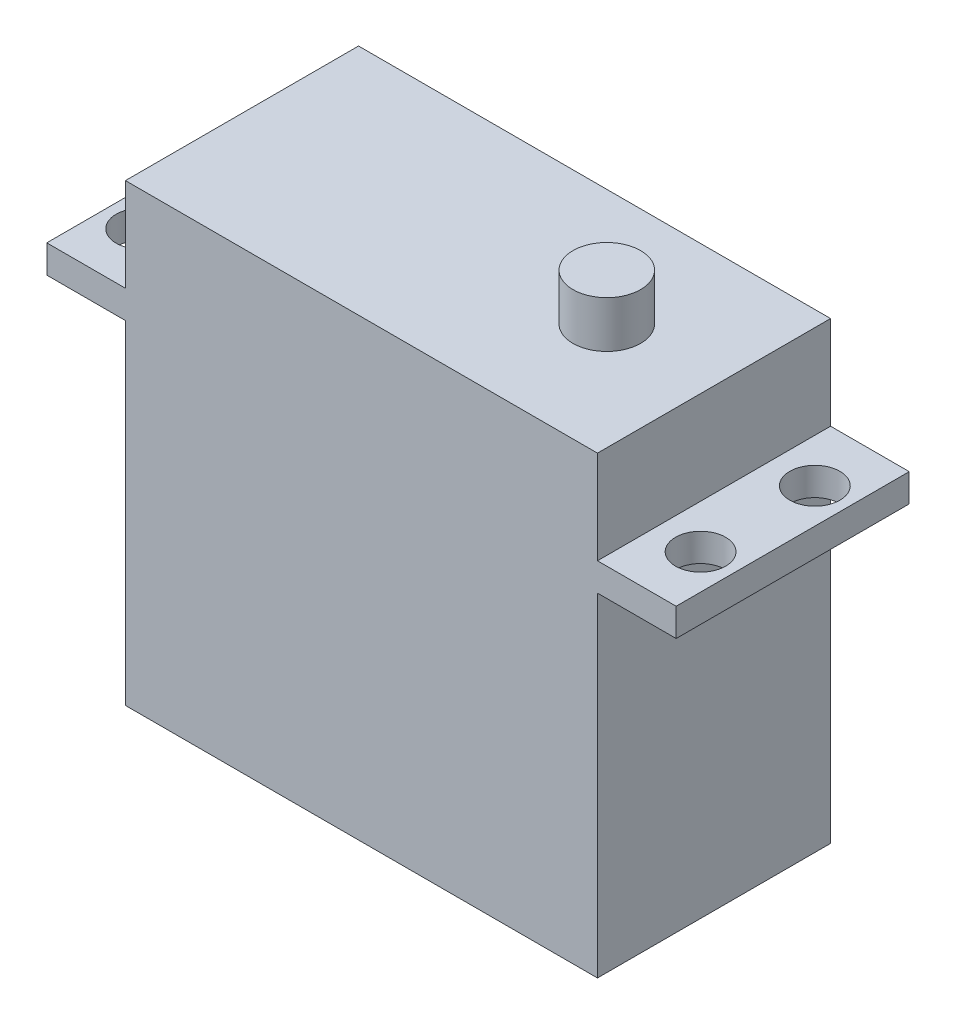
from build123d import *

# Parameters (mm, degrees)
SKETCH_1_W          = 40.5
SKETCH_1_H          = 20
EXTRUDE_1_DEPTH     = 28.6
SKETCH_2_W          = 54
SKETCH_2_H          = 20
EXTRUDE_2_DEPTH     = 2.4
SKETCH_3_W          = 40.5
SKETCH_3_H          = 20
EXTRUDE_3_DEPTH     = 8
SKETCH_4_R          = 2.9
EXTRUDE_4_DEPTH     = 4
SKETCH_5_R          = 2.15
CUT_EXTRUDE_1_DEPTH = 32


with BuildPart() as part:
    # 草图1 → 凸台-拉伸1 (new body)
    with BuildSketch(Plane(origin=(0, 0, 0), x_dir=(1, 0, 0), z_dir=(0, 1, 0))):
        Rectangle(SKETCH_1_W, SKETCH_1_H)
    extrude(amount=EXTRUDE_1_DEPTH)

    # 草图2 → 凸台-拉伸2 (add)
    with BuildSketch(Plane(origin=(0, 28.6, 0), x_dir=(1, 0, 0), z_dir=(0, 1, 0))):
        Rectangle(SKETCH_2_W, SKETCH_2_H)
    extrude(amount=EXTRUDE_2_DEPTH)

    # 草图3 → 凸台-拉伸3 (add)
    with BuildSketch(Plane(origin=(0, 31, 0), x_dir=(1, 0, 0), z_dir=(0, 1, 0))):
        Rectangle(SKETCH_3_W, SKETCH_3_H)
    extrude(amount=EXTRUDE_3_DEPTH)

    # 草图4 → 凸台-拉伸4 (add)
    with BuildSketch(Plane(origin=(0, 39, 0), x_dir=(1, 0, 0), z_dir=(0, 1, 0))):
        with Locations((11.05, 0)):
            Circle(SKETCH_4_R)
    extrude(amount=EXTRUDE_4_DEPTH)

    # 草图5 → 切除-拉伸1 (cut, through all)
    with BuildSketch(Plane(origin=(0, 31, 0), x_dir=(1, 0, 0), z_dir=(0, 1, 0))):
        with Locations((24, 4.9)):
            Circle(SKETCH_5_R)
        with Locations((24, -4.9)):
            Circle(SKETCH_5_R)
        with Locations((-24, -4.9)):
            Circle(SKETCH_5_R)
        with Locations((-24, 4.9)):
            Circle(SKETCH_5_R)
    extrude(amount=-CUT_EXTRUDE_1_DEPTH, mode=Mode.SUBTRACT)


solid = part.part
